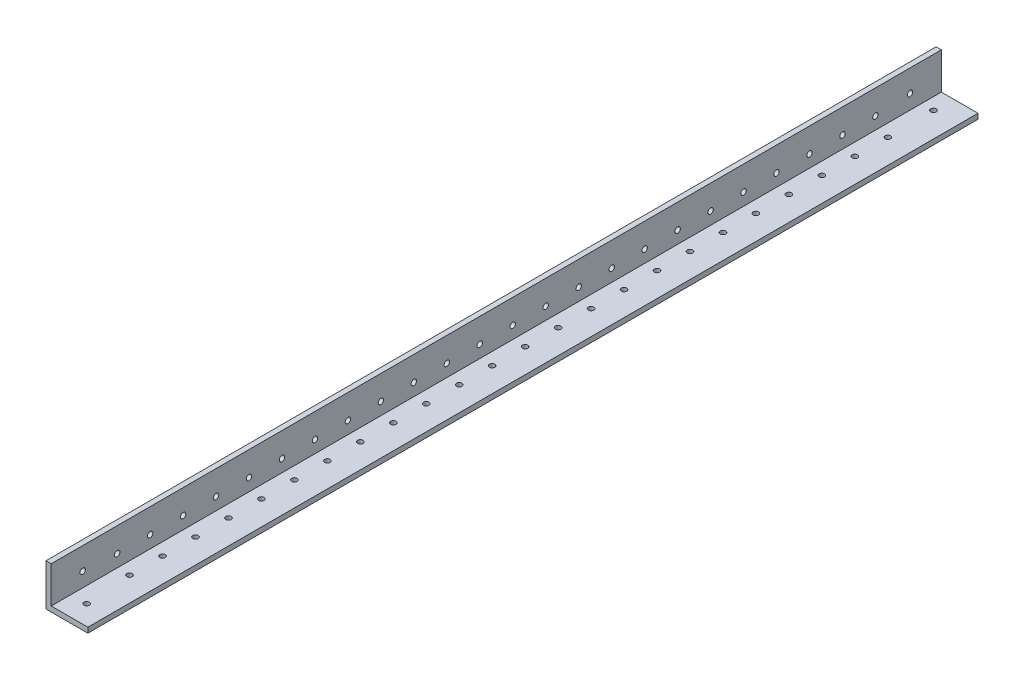
from build123d import *

# Parameters (mm, degrees)
BOSS_EXTRUDE1_DEPTH = 1219.2
FILLET1_R           = 0.4064
SKETCH4_W           = 1898.4
SKETCH4_H           = 103.278519729
CUT_EXTRUDE1_DEPTH  = 60
SKETCH5_W           = 2.47699065
SKETCH5_H           = 2.94685794
CUT_EXTRUDE2_DEPTH  = 600
SKETCH8_R           = 1.65
CUT_EXTRUDE4_DEPTH  = 20
SKETCH9_R           = 1.65
CUT_EXTRUDE5_DEPTH  = 20
SKETCH10_R          = 1.65
CUT_EXTRUDE6_DEPTH  = 70
SKETCH11_R          = 1.65
CUT_EXTRUDE7_DEPTH  = 70


with BuildPart() as part:
    # Sketch3 → Boss-Extrude1 (new, symmetric)
    with BuildSketch(Plane.XY):
        Polygon((3.175, 25.4), (0, 25.4), (0, 0), (25.4, 0), (25.4, 3.175), (3.175, 3.175), align=None)
    extrude(amount=BOSS_EXTRUDE1_DEPTH, both=True)

    # Fillet1
    fillet1_edges = [part.edges().sort_by_distance(p)[0] for p in [
        (3.175, 3.175, 0),
    ]]
    fillet(fillet1_edges, radius=FILLET1_R)

    # Sketch4 → Cut-Extrude1 (cut)
    with BuildSketch(Plane.ZY):
        with Locations((-270, -26.239259864)):
            Rectangle(SKETCH4_W, SKETCH4_H)
    extrude(amount=-CUT_EXTRUDE1_DEPTH, mode=Mode.SUBTRACT)

    # Sketch5 → Cut-Extrude2 (cut)
    with BuildSketch(Plane(origin=(0, 0, 679.2), x_dir=(-1, 0, 0), z_dir=(0, 0, -1))):
        with Locations((-4.413495325, 4.64842897)):
            Rectangle(SKETCH5_W, SKETCH5_H)
    extrude(amount=-CUT_EXTRUDE2_DEPTH, mode=Mode.SUBTRACT)

    # Sketch8 → Cut-Extrude4 (cut)
    with BuildSketch(Plane(origin=(3.175, 0, 0), x_dir=(0, 0, -1), z_dir=(1, 0, 0))):
        with Locations(Location((-1179.2, 10.675, 0), (0, 0, 90))):
            Circle(SKETCH8_R)
        with Locations(Location((-1159.2, 10.675, 0), (0, 0, 90))):
            Circle(SKETCH8_R)
        with Locations(Location((-1139.2, 10.675, 0), (0, 0, 90))):
            Circle(SKETCH8_R)
        with Locations(Location((-1119.2, 10.675, 0), (0, 0, 90))):
            Circle(SKETCH8_R)
        with Locations(Location((-1099.2, 10.675, 0), (0, 0, 90))):
            Circle(SKETCH8_R)
        with Locations(Location((-1079.2, 10.675, 0), (0, 0, 90))):
            Circle(SKETCH8_R)
        with Locations(Location((-1059.2, 10.675, 0), (0, 0, 90))):
            Circle(SKETCH8_R)
        with Locations(Location((-1039.2, 10.675, 0), (0, 0, 90))):
            Circle(SKETCH8_R)
        with Locations(Location((-1019.2, 10.675, 0), (0, 0, 90))):
            Circle(SKETCH8_R)
        with Locations(Location((-999.2, 10.675, 0), (0, 0, 90))):
            Circle(SKETCH8_R)
        with Locations(Location((-979.2, 10.675, 0), (0, 0, 90))):
            Circle(SKETCH8_R)
        with Locations(Location((-959.2, 10.675, 0), (0, 0, 90))):
            Circle(SKETCH8_R)
        with Locations(Location((-939.2, 10.675, 0), (0, 0, 90))):
            Circle(SKETCH8_R)
        with Locations(Location((-919.2, 10.675, 0), (0, 0, 90))):
            Circle(SKETCH8_R)
        with Locations(Location((-899.2, 10.675, 0), (0, 0, 90))):
            Circle(SKETCH8_R)
        with Locations(Location((-879.2, 10.675, 0), (0, 0, 90))):
            Circle(SKETCH8_R)
        with Locations(Location((-859.2, 10.675, 0), (0, 0, 90))):
            Circle(SKETCH8_R)
        with Locations(Location((-839.2, 10.675, 0), (0, 0, 90))):
            Circle(SKETCH8_R)
        with Locations(Location((-819.2, 10.675, 0), (0, 0, 90))):
            Circle(SKETCH8_R)
        with Locations(Location((-799.2, 10.675, 0), (0, 0, 90))):
            Circle(SKETCH8_R)
        with Locations(Location((-779.2, 10.675, 0), (0, 0, 90))):
            Circle(SKETCH8_R)
        with Locations(Location((-759.2, 10.675, 0), (0, 0, 90))):
            Circle(SKETCH8_R)
        with Locations(Location((-739.2, 10.675, 0), (0, 0, 90))):
            Circle(SKETCH8_R)
        with Locations(Location((-719.2, 10.675, 0), (0, 0, 90))):
            Circle(SKETCH8_R)
    extrude(amount=-CUT_EXTRUDE4_DEPTH, mode=Mode.SUBTRACT)

    # Sketch9 → Cut-Extrude5 (cut)
    with BuildSketch(Plane(origin=(0, 3.175, 0), x_dir=(1, 0, 0), z_dir=(0, 1, 0))):
        with Locations(Location((10.675, -1179.2, 0), (0, 0, 180))):
            Circle(SKETCH9_R)
        with Locations(Location((10.675, -1159.2, 0), (0, 0, 180))):
            Circle(SKETCH9_R)
        with Locations(Location((10.675, -1139.2, 0), (0, 0, 180))):
            Circle(SKETCH9_R)
        with Locations(Location((10.675, -1119.2, 0), (0, 0, 180))):
            Circle(SKETCH9_R)
        with Locations(Location((10.675, -1099.2, 0), (0, 0, 180))):
            Circle(SKETCH9_R)
        with Locations(Location((10.675, -1079.2, 0), (0, 0, 180))):
            Circle(SKETCH9_R)
        with Locations(Location((10.675, -1059.2, 0), (0, 0, 180))):
            Circle(SKETCH9_R)
        with Locations(Location((10.675, -1039.2, 0), (0, 0, 180))):
            Circle(SKETCH9_R)
        with Locations(Location((10.675, -1019.2, 0), (0, 0, 180))):
            Circle(SKETCH9_R)
        with Locations(Location((10.675, -999.2, 0), (0, 0, 180))):
            Circle(SKETCH9_R)
        with Locations(Location((10.675, -979.2, 0), (0, 0, 180))):
            Circle(SKETCH9_R)
        with Locations(Location((10.675, -959.2, 0), (0, 0, 180))):
            Circle(SKETCH9_R)
        with Locations(Location((10.675, -939.2, 0), (0, 0, 180))):
            Circle(SKETCH9_R)
        with Locations(Location((10.675, -919.2, 0), (0, 0, 180))):
            Circle(SKETCH9_R)
        with Locations(Location((10.675, -899.2, 0), (0, 0, 180))):
            Circle(SKETCH9_R)
        with Locations(Location((10.675, -879.2, 0), (0, 0, 180))):
            Circle(SKETCH9_R)
        with Locations(Location((10.675, -859.2, 0), (0, 0, 180))):
            Circle(SKETCH9_R)
        with Locations(Location((10.675, -839.2, 0), (0, 0, 180))):
            Circle(SKETCH9_R)
        with Locations(Location((10.675, -819.2, 0), (0, 0, 180))):
            Circle(SKETCH9_R)
        with Locations(Location((10.675, -799.2, 0), (0, 0, 180))):
            Circle(SKETCH9_R)
        with Locations(Location((10.675, -779.2, 0), (0, 0, 180))):
            Circle(SKETCH9_R)
        with Locations(Location((10.675, -759.2, 0), (0, 0, 180))):
            Circle(SKETCH9_R)
        with Locations(Location((10.675, -739.2, 0), (0, 0, 180))):
            Circle(SKETCH9_R)
        with Locations(Location((10.675, -719.2, 0), (0, 0, 180))):
            Circle(SKETCH9_R)
    extrude(amount=-CUT_EXTRUDE5_DEPTH, mode=Mode.SUBTRACT)

    # Sketch10 → Cut-Extrude6 (cut)
    with BuildSketch(Plane(origin=(3.175, 0, 0), x_dir=(0, 0, -1), z_dir=(1, 0, 0))):
        with Locations(Location((-1200.15, 11.9634, 0), (0, 0, 90))):
            Circle(SKETCH10_R)
        with Locations(Location((-698.25, 11.9634, 0), (0, 0, 90))):
            Circle(SKETCH10_R)
    extrude(amount=-CUT_EXTRUDE6_DEPTH, mode=Mode.SUBTRACT)

    # Sketch11 → Cut-Extrude7 (cut)
    with BuildSketch(Plane(origin=(0, 3.175, 0), x_dir=(1, 0, 0), z_dir=(0, 1, 0))):
        with Locations(Location((10.364377143, -691.195704333, 0), (0, 0, 180))):
            Circle(SKETCH11_R)
        with Locations(Location((12.7, -1207.204295667, 0), (0, 0, 180))):
            Circle(SKETCH11_R)
    extrude(amount=-CUT_EXTRUDE7_DEPTH, mode=Mode.SUBTRACT)


solid = part.part
